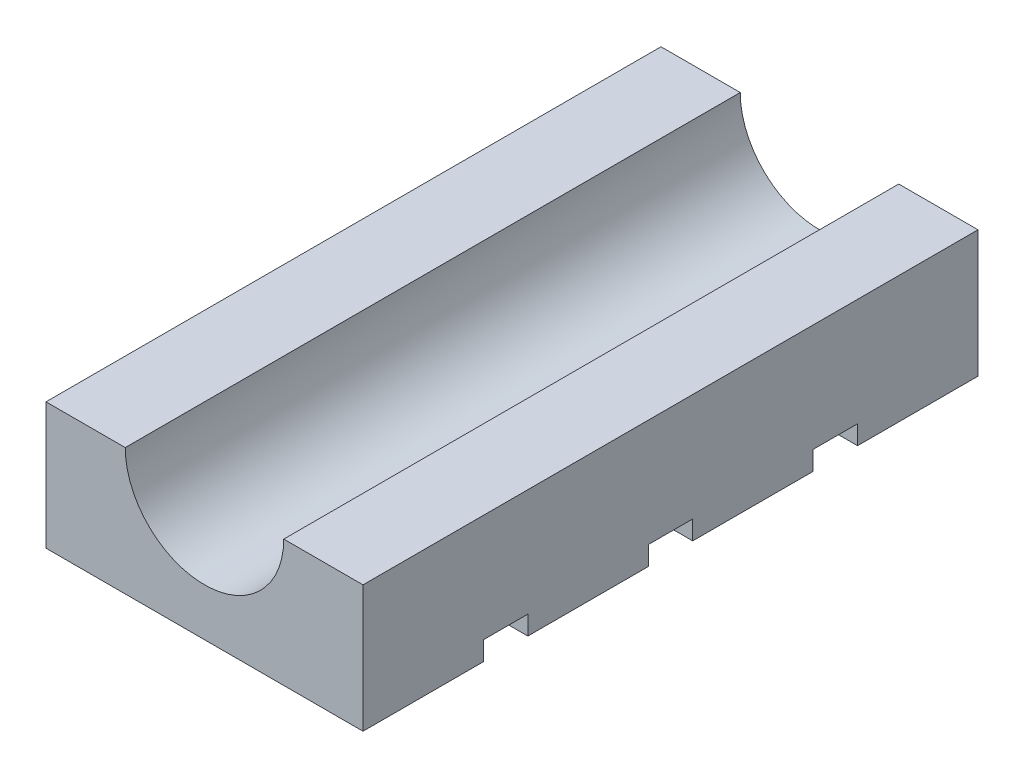
from build123d import *

# Parameters (mm, degrees)
SKETCH1_W           = 50
SKETCH1_H           = 97
BOSS_EXTRUDE1_DEPTH = 20
SKETCH2_R           = 12.5
CUT_EXTRUDE1_DEPTH  = 100
SKETCH3_W           = 50
SKETCH3_H           = 7
CUT_EXTRUDE2_DEPTH  = 3


with BuildPart() as part:
    # Sketch1 → Boss-Extrude1 (new body)
    with BuildSketch(Plane(origin=(0, 0, 0), x_dir=(1, 0, 0), z_dir=(0, 1, 0))):
        with Locations((25, -48.5)):
            Rectangle(SKETCH1_W, SKETCH1_H)
    extrude(amount=BOSS_EXTRUDE1_DEPTH)

    # Sketch2 → Cut-Extrude1 (cut)
    with BuildSketch(Plane.XY.offset(97)):
        with Locations((25, 20)):
            Circle(SKETCH2_R)
    extrude(amount=-CUT_EXTRUDE1_DEPTH, mode=Mode.SUBTRACT)

    # Sketch3 → Cut-Extrude2 (cut)
    with BuildSketch(Plane.XZ):
        with Locations((25, 74.5)):
            Rectangle(SKETCH3_W, SKETCH3_H)
        with Locations((25, 48.5)):
            Rectangle(SKETCH3_W, SKETCH3_H)
        with Locations((25, 22.5)):
            Rectangle(SKETCH3_W, SKETCH3_H)
    extrude(amount=-CUT_EXTRUDE2_DEPTH, mode=Mode.SUBTRACT)


solid = part.part
